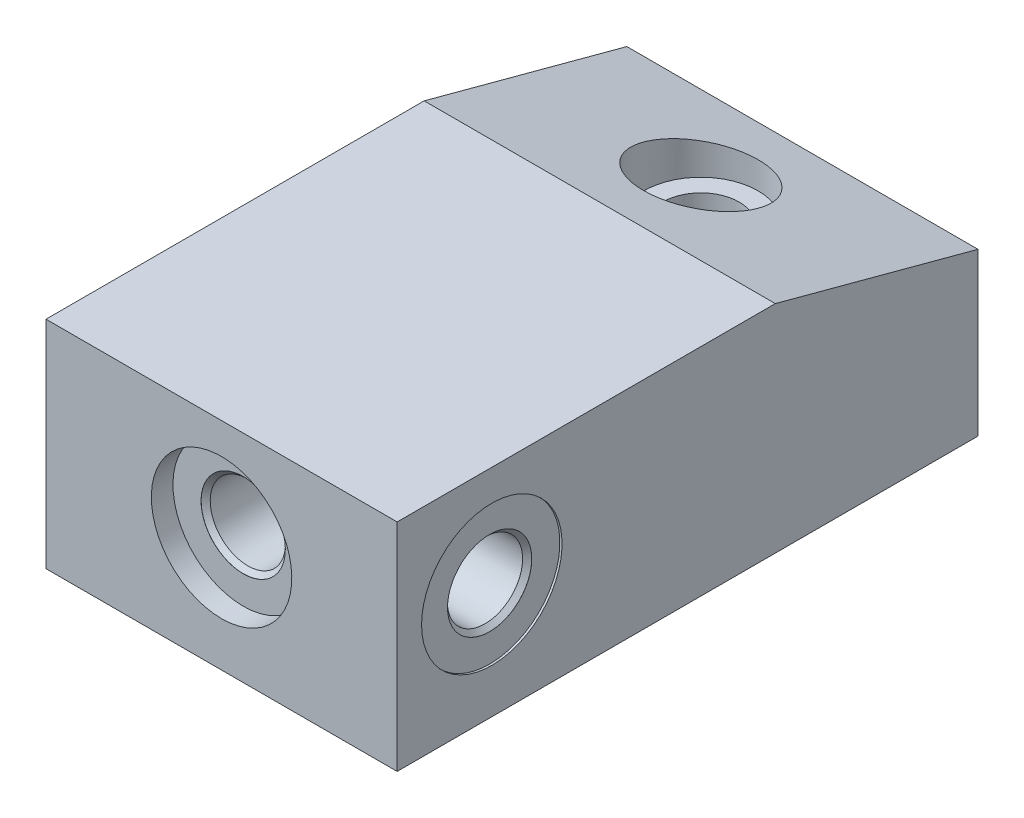
from build123d import *

# Parameters (mm, degrees)
EXTRUDE1_DEPTH      = 20.6375
EXTRUDE1_DEPTH_BACK = 20.6375
CUT_EXTRUDE1_REACH  = 27.4
SKETCH4_R           = 7.99973
SKETCH4_R_2         = 4.3688
EXTRUDE2_DEPTH      = 9.144
EXTRUDE3_DEPTH      = 7.925
EXTRUDE3_DEPTH_BACK = 7.925
CUT_EXTRUDE2_DEPTH  = 24.765
LPATTERN2_COUNT     = 3
LPATTERN2_PITCH     = 1.5875
FILLET1_R           = 0.7874
SKETCH11_R          = 3.3145
CUT_EXTRUDE3_DEPTH  = 4.7498


with BuildPart() as part:
    # Sketch1 → Extrude1 (new body, two sides)
    with BuildSketch(Plane(origin=(0, 0, 0), x_dir=(0, 0, -1), z_dir=(1, 0, 0))) as extrude1_sk:
        Polygon((44.45, 25.4), (68.273015024, 19.016642363), (68.273015024, 12.442638617), (70.6374, 11.809103573), (70.6374, 0), (0, 0), (0, 25.4), align=None)
    extrude(amount=EXTRUDE1_DEPTH)
    extrude(extrude1_sk.sketch, amount=-EXTRUDE1_DEPTH_BACK)

    # Cut-Extrude1: up to this plane
    cut_extrude1_end = Plane(origin=(-20.6375, 12.442638617, -68.273015024), z_dir=(0, 0.965925826, -0.258819045))
    # Sketch2 → Cut-Extrude1 (cut, up to the surface)
    with BuildSketch(Plane.XZ, mode=Mode.PRIVATE) as cut_extrude1_sk1:
        with BuildLine():
            Line((20.6375, -70.6374), (12.7, -70.6374))
            ThreePointArc((12.7, -70.6374), (13.832391453, -68.932629596), (15.769776585, -68.273015024))
            Line((15.769776585, -68.273015024), (20.6375, -68.273015024))
            Line((20.6375, -68.273015024), (20.6375, -70.6374))
        make_face()
    cut_extrude1_tool1 = split(extrude(cut_extrude1_sk1.sketch, amount=-CUT_EXTRUDE1_REACH, mode=Mode.PRIVATE), bisect_by=cut_extrude1_end, keep=Keep.BOTH, mode=Mode.PRIVATE)
    add(cut_extrude1_tool1.solids().sort_by_distance((17.033922, 0, -69.518139))[0], mode=Mode.SUBTRACT)
    # Sketch2 → Cut-Extrude1 (cut, up to the surface)
    with BuildSketch(Plane.XZ, mode=Mode.PRIVATE) as cut_extrude1_sk2:
        with BuildLine():
            Line((-20.6375, -68.273015024), (-15.769776585, -68.273015024))
            ThreePointArc((-15.769776585, -68.273015024), (-13.832391453, -68.932629596), (-12.7, -70.6374))
            Line((-12.7, -70.6374), (-20.6375, -70.6374))
            Line((-20.6375, -70.6374), (-20.6375, -68.273015024))
        make_face()
    cut_extrude1_tool2 = split(extrude(cut_extrude1_sk2.sketch, amount=-CUT_EXTRUDE1_REACH, mode=Mode.PRIVATE), bisect_by=cut_extrude1_end, keep=Keep.BOTH, mode=Mode.PRIVATE)
    add(cut_extrude1_tool2.solids().sort_by_distance((-17.033922, 0, -69.518139))[0], mode=Mode.SUBTRACT)

    # Sketch3 → Cut-Revolve1 (revolve, cut)
    with BuildSketch(Plane(origin=(0, 0, 0), x_dir=(0, 0, -1), z_dir=(1, 0, 0)), mode=Mode.PRIVATE) as cut_revolve1_sk:
        Polygon((49.5937, 24.021749739), (49.5937, 17.232918978), (51.8412, 17.232918978), (51.8412, 3.175), (48.3616, 3.175), (48.3616, 0), (56.3372, 0), (56.3372, 24.021749739), align=None)
    revolve(cut_revolve1_sk.sketch.rotate(Axis((0, -4.910727806, -56.3372), (0, 1, 0)), 180), axis=Axis((0, -4.910727806, -56.3372), (0, 1, 0)), mode=Mode.SUBTRACT)  # turned: the seam where the file's is

    # Sketch4 → Extrude2 (add)
    with BuildSketch(Plane.XZ.offset(-3.175)):
        with Locations(Location((0, -56.3372, 0), (0, 0, 270))):  # turned: the seam where the file's is
            Circle(SKETCH4_R)
        with Locations(Location((0, -56.3372, 0), (0, 0, 270))):  # turned: the seam where the file's is
            Circle(SKETCH4_R_2, mode=Mode.SUBTRACT)
    extrude(amount=EXTRUDE2_DEPTH)

    # Sketch6 → Extrude3 (add, two sides)
    with BuildSketch(Plane(origin=(0, 0, 0), x_dir=(0, 0, -1), z_dir=(1, 0, 0))) as extrude3_sk:
        Polygon((70.6374, 2.789570434), (75.4126, 1.51005945), (75.4126, 8.12340369), (70.6374, 9.402914674), align=None)
    extrude(amount=EXTRUDE3_DEPTH)
    extrude(extrude3_sk.sketch, amount=-EXTRUDE3_DEPTH_BACK)

    # Sketch7 → Cut-Extrude2 (cut, symmetric)
    with BuildSketch(Plane(origin=(0, 0, 0), x_dir=(0, 0, -1), z_dir=(1, 0, 0))):
        Polygon((75.4126, 3.49443445), (75.4126, 2.70068445), (74.61885, 2.913369121), (74.61885, 3.281749778), align=None)
    cut_extrude2 = extrude(amount=CUT_EXTRUDE2_DEPTH, both=True, mode=Mode.SUBTRACT)

    # LPattern2: Cut-Extrude2 ×3
    with Locations(*[(0, i * LPATTERN2_PITCH, 0) for i in range(1, LPATTERN2_COUNT)]):
        add(cut_extrude2, mode=Mode.SUBTRACT)

    # Fillet1
    fillet1_edges = [part.edges().sort_by_distance(p)[0] for p in [
        (0, 8.12340369, -75.4126),
        (0, 1.51005945, -75.4126),
    ]]
    fillet(fillet1_edges, radius=FILLET1_R)

    # Sketch11 → Cut-Extrude3 (cut)
    with BuildSketch(Plane.XZ):
        with Locations(Location((0, -8.7122, 0), (0, 0, 270))):  # turned: the seam where the file's is
            Circle(SKETCH11_R)
    extrude(amount=-CUT_EXTRUDE3_DEPTH, mode=Mode.SUBTRACT)

    # Sketch12 → Cut-Revolve2 (revolve, cut)
    with BuildSketch(Plane(origin=(0, 0, 0), x_dir=(0, 0, -1), z_dir=(1, 0, 0)), mode=Mode.PRIVATE) as cut_revolve2_sk:
        Polygon((0, 21.7424), (2.54, 21.7424), (2.54, 18.4404), (2.55, 18.4404), (3.0835, 17.9069), (13.106, 17.9069), (13.106, 13.4874), (0, 13.4874), align=None)
    revolve(cut_revolve2_sk.sketch.rotate(Axis((0, 13.4874, 3.668396013), (0, 0, -1)), 180), axis=Axis((0, 13.4874, 3.668396013), (0, 0, -1)), mode=Mode.SUBTRACT)  # turned: the seam where the file's is

    # Sketch13 → Cut-Revolve3 (revolve, cut)
    with BuildSketch(Plane.XY.offset(-11.1252), mode=Mode.PRIVATE) as cut_revolve3_sk:
        Polygon((20.6375, 21.7424), (20.3835, 21.7424), (20.3835, 18.4404), (20.3735, 18.4404), (19.84, 17.9069), (9.8175, 17.9069), (9.8175, 13.4874), (20.6375, 13.4874), align=None)
        Polygon((-20.6375, 13.4874), (-20.6375, 21.7424), (-20.3835, 21.7424), (-20.3835, 18.4404), (-20.3735, 18.4404), (-19.84, 17.9069), (-9.8175, 17.9069), (-9.8175, 13.4874), align=None)
    revolve(cut_revolve3_sk.sketch.rotate(Axis((0, 13.4874, -11.1252), (1, 0, 0)), 90), axis=Axis((0, 13.4874, -11.1252), (1, 0, 0)), mode=Mode.SUBTRACT)  # turned: the seam where the file's is


solid = part.part
